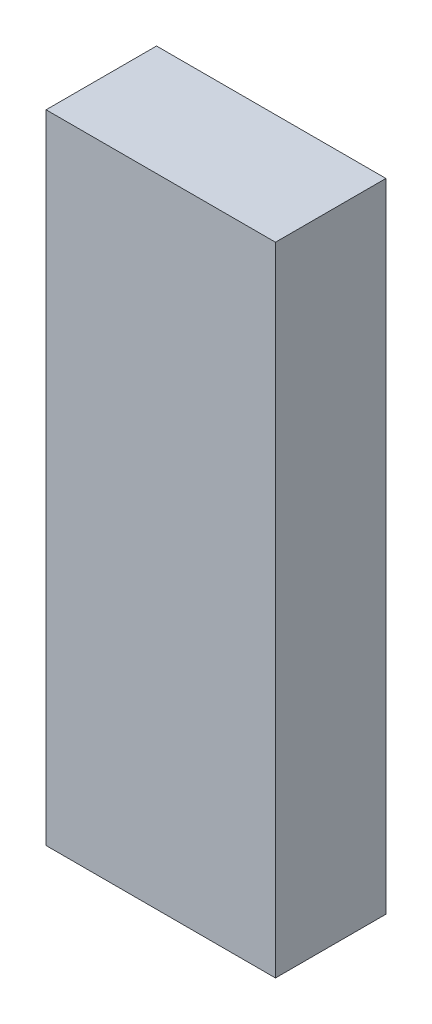
from build123d import *

# Parameters (mm, degrees)
ESQUISSE1_W        = 27
ESQUISSE1_H        = 13
BOSS_EXTRU_1_DEPTH = 75


with BuildPart() as part:
    # Esquisse1 → Boss.-Extru.1 (new body)
    with BuildSketch(Plane(origin=(0, 0, 0), x_dir=(1, 0, 0), z_dir=(0, 1, 0))):
        with Locations((13.5, 6.5)):
            Rectangle(ESQUISSE1_W, ESQUISSE1_H)
    extrude(amount=BOSS_EXTRU_1_DEPTH)


solid = part.part
